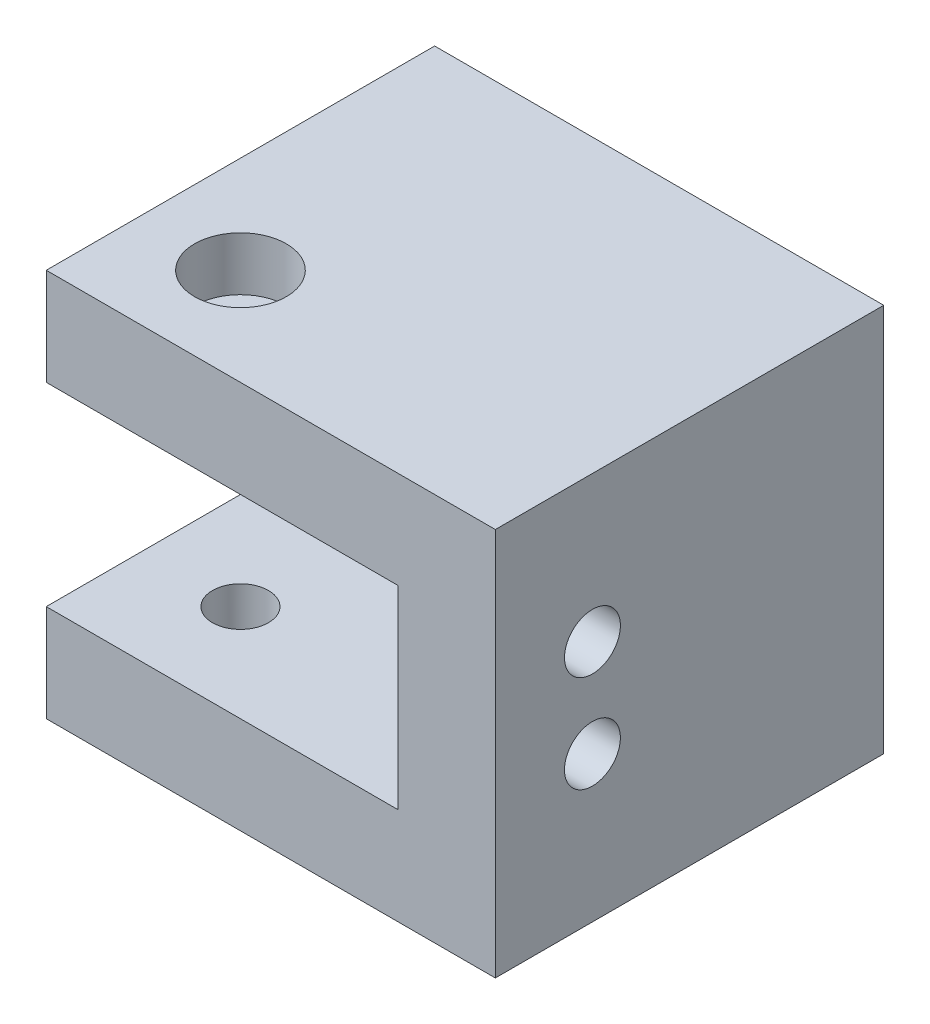
from build123d import *

# Parameters (mm, degrees)
SKETCH1_W                                      = 29.36875
SKETCH1_H                                      = 25.4
BOSS_EXTRUDE1_DEPTH                            = 25.4
SKETCH2_W                                      = 23.01875
SKETCH2_H                                      = 12.7
CUT_EXTRUDE1_DEPTH                             = 15.875
CBORE_FOR_6_SOCKET_HEAD_CAP_SCREW1_D           = 3.6576
CBORE_FOR_6_SOCKET_HEAD_CAP_SCREW1_CBORE_D     = 5.999999938
CBORE_FOR_6_SOCKET_HEAD_CAP_SCREW1_CBORE_DEPTH = 3.5052
F_6_CLEARANCE_HOLE2_D                          = 3.6576
FILLET1_R                                      = 3.175
TAP_DRILL_FOR_1_4_20_TAP2_D                    = 5.1054


with BuildPart() as part:
    # Sketch1 → Boss-Extrude1 (new body)
    with BuildSketch(Plane.XY):
        with Locations((14.684375, 12.7)):
            Rectangle(SKETCH1_W, SKETCH1_H)
    extrude(amount=BOSS_EXTRUDE1_DEPTH)

    # Sketch2 → Cut-Extrude1 (cut)
    with BuildSketch(Plane.XY.offset(25.4)):
        with Locations((11.509375, 12.7)):
            Rectangle(SKETCH2_W, SKETCH2_H)
    extrude(amount=-CUT_EXTRUDE1_DEPTH, mode=Mode.SUBTRACT)

    # CBORE for #6 Socket Head Cap Screw1 (through all)
    with Locations(Plane(origin=(0, 25.4, 0), x_dir=(1, 0, 0), z_dir=(0, 1, 0))):
        with Locations((6.35, -19.05)):
            CounterBoreHole(CBORE_FOR_6_SOCKET_HEAD_CAP_SCREW1_D / 2, CBORE_FOR_6_SOCKET_HEAD_CAP_SCREW1_CBORE_D / 2, CBORE_FOR_6_SOCKET_HEAD_CAP_SCREW1_CBORE_DEPTH)

    # #6 Clearance Hole2 (through all)
    with Locations(Plane(origin=(29.36875, 0, 0), x_dir=(0, 0, -1), z_dir=(1, 0, 0))):
        with Locations((-19.05, 15.875), (-19.05, 9.525)):
            Hole(F_6_CLEARANCE_HOLE2_D / 2)

    # Fillet1
    fillet1_edges = [part.edges().sort_by_distance(p)[0] for p in [
        (11.509375, 19.05, 9.525),
        (11.509375, 6.35, 9.525),
    ]]
    fillet(fillet1_edges, radius=FILLET1_R)

    # Tap Drill for 1/4-20 Tap2 (through all)
    with Locations(Plane.XY.offset(9.525)):
        with Locations((6.35, 12.7), (17.78, 12.7)):
            Hole(TAP_DRILL_FOR_1_4_20_TAP2_D / 2)


solid = part.part
